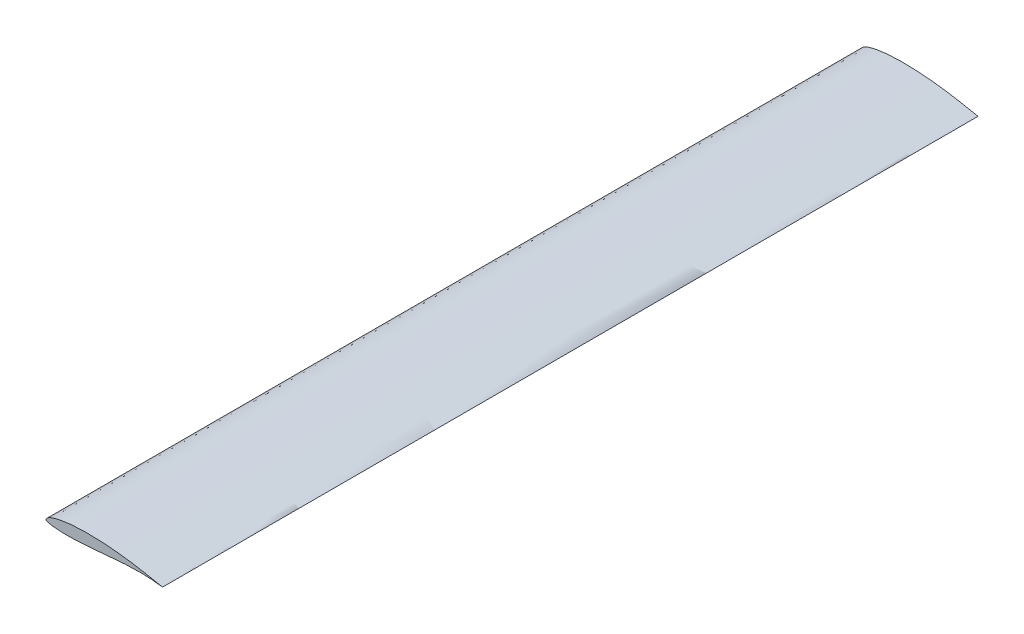
from build123d import *

# Parameters (mm, degrees)
BOSS_EXTRUDE1_DEPTH = 1147.5


with BuildPart() as part:
    # Sketch2 → Boss-Extrude1 (new body)
    with BuildSketch(Plane.XY):
        with BuildLine():
            add(Edge.make_bspline(
                [(164, 0), (164.001991598, 0.00531985), (162.498434343, 0.297400203), (160.966285987, 0.616919952), (157.230075916, 1.35854981), (152.647727614, 2.276655229), (146.674778271, 3.452593401), (139.663921431, 4.788107638), (131.643002502, 6.225523454), (122.779722168, 7.678120549), (113.214717928, 9.062609537), (103.114761216, 10.30867808), (92.653330955, 11.366874663), (82.008680624, 12.183570909), (71.363717138, 12.732678494), (62.573062305, 12.938820128), (55.679219616, 12.931629583), (50.66379262, 12.839728664), (45.782181562, 12.659463205), (41.055239208, 12.3903785), (36.503682969, 12.036437473), (32.146930875, 11.601780671), (28.004239994, 11.085142861), (24.091702865, 10.49834901), (20.426822474, 9.843918183), (17.025844132, 9.130833564), (13.902230709, 8.369358841), (11.06833563, 7.565562996), (8.53577437, 6.720118621), (6.312379055, 5.832916092), (4.413351959, 4.89013994), (2.84511205, 3.903245047), (1.620457598, 2.901127061), (0.731165093, 1.938080692), (0.179493112, 1.068674431), (-0.069462085, 0.284825746), (0.1340338, -0.423690631), (0.764071957, -0.903152486), (1.66761423, -1.285012606), (2.89636931, -1.667860408), (4.454368995, -2.060754755), (6.342184668, -2.463268111), (8.554678564, -2.849189029), (11.082153575, -3.197036089), (13.91354845, -3.489623602), (17.035473755, -3.733426896), (20.435651878, -3.919184892), (24.099392464, -4.054926113), (28.010855137, -4.127538534), (32.152921407, -4.140988099), (36.508800602, -4.082499209), (41.059834749, -3.949191021), (45.786267855, -3.736710609), (50.667246714, -3.44561856), (55.681487768, -3.077952812), (62.575429044, -2.5099648), (71.360013547, -1.687848394), (81.99774075, -0.654631351), (92.636555888, 0.330119403), (103.095163283, 1.174218069), (113.195150773, 1.80138175), (122.763237889, 2.175762051), (131.632477935, 2.284101672), (139.659679629, 2.147275472), (146.676584213, 1.826335034), (152.651459073, 1.377599866), (157.237589271, 0.924994424), (160.965141957, 0.442021742), (162.505368274, 0.239871333), (163.998025246, -0.005274856), (164, 0)],
                knots=[0, 0, 0, 0, 0.002148054, 0.008549751, 0.019093203, 0.033601904, 0.051811667, 0.073403086, 0.097969443, 0.125069858, 0.154220145, 0.184909694, 0.216620256, 0.248810746, 0.280948927, 0.312507484, 0.327906501, 0.342968756, 0.35763527, 0.371852485, 0.385561874, 0.398705235, 0.41124018, 0.423117643, 0.434295112, 0.444729135, 0.454375798, 0.463214982, 0.47122318, 0.478387129, 0.484734913, 0.490272765, 0.495019578, 0.498937389, 0.50200172, 0.504262281, 0.506099972, 0.508217729, 0.511109021, 0.514949183, 0.519768397, 0.525567786, 0.532308947, 0.539970427, 0.548516152, 0.557914396, 0.568140585, 0.579150255, 0.590897187, 0.603335474, 0.616414202, 0.630087791, 0.644295999, 0.65897818, 0.674077354, 0.689528147, 0.721210905, 0.753454187, 0.785684185, 0.817334233, 0.847849866, 0.876721279, 0.903468398, 0.927655074, 0.948890459, 0.966808427, 0.981110174, 0.991529529, 0.997870113, 1, 1, 1, 1], degree=3))
        make_face()
    extrude(amount=BOSS_EXTRUDE1_DEPTH)


solid = part.part
